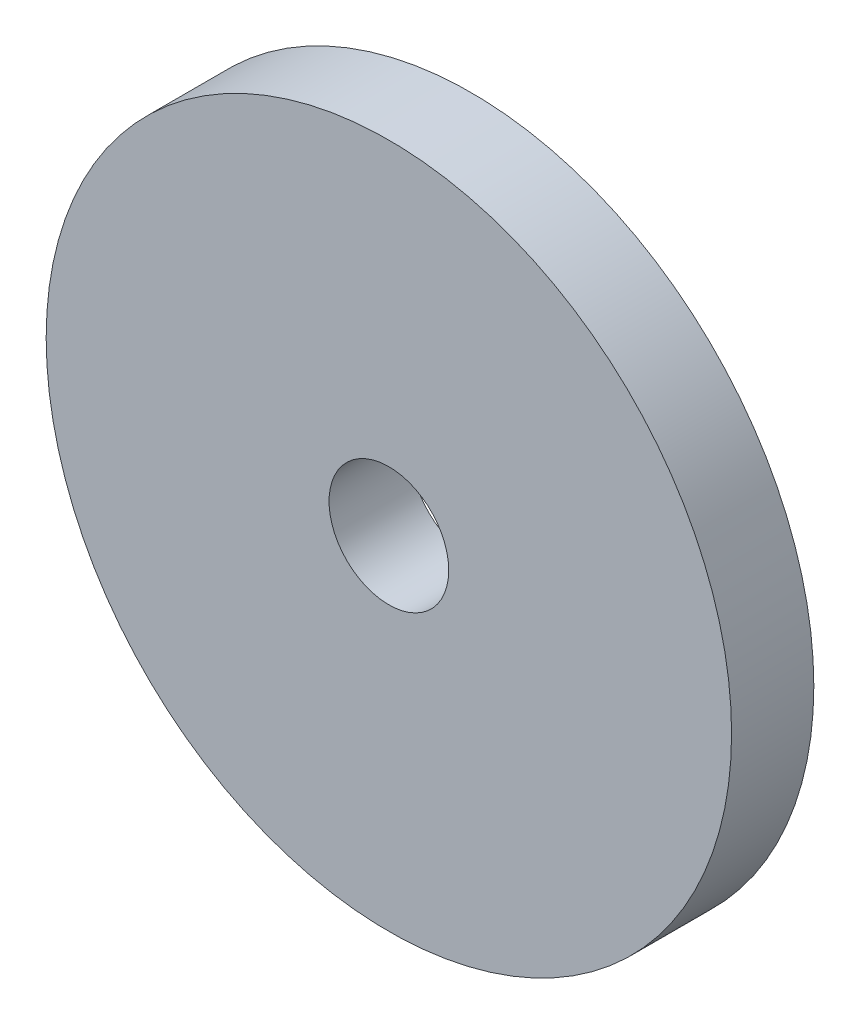
from build123d import *

# Parameters (mm, degrees)
SKETCH1_R           = 31.75
SKETCH1_R_2         = 5.543255405
BOSS_EXTRUDE1_DEPTH = 7.62


with BuildPart() as part:
    # Sketch1 → Boss-Extrude1 (new body)
    with BuildSketch(Plane.XY):
        Circle(SKETCH1_R)
        Circle(SKETCH1_R_2, mode=Mode.SUBTRACT)
    extrude(amount=BOSS_EXTRUDE1_DEPTH)


solid = part.part
